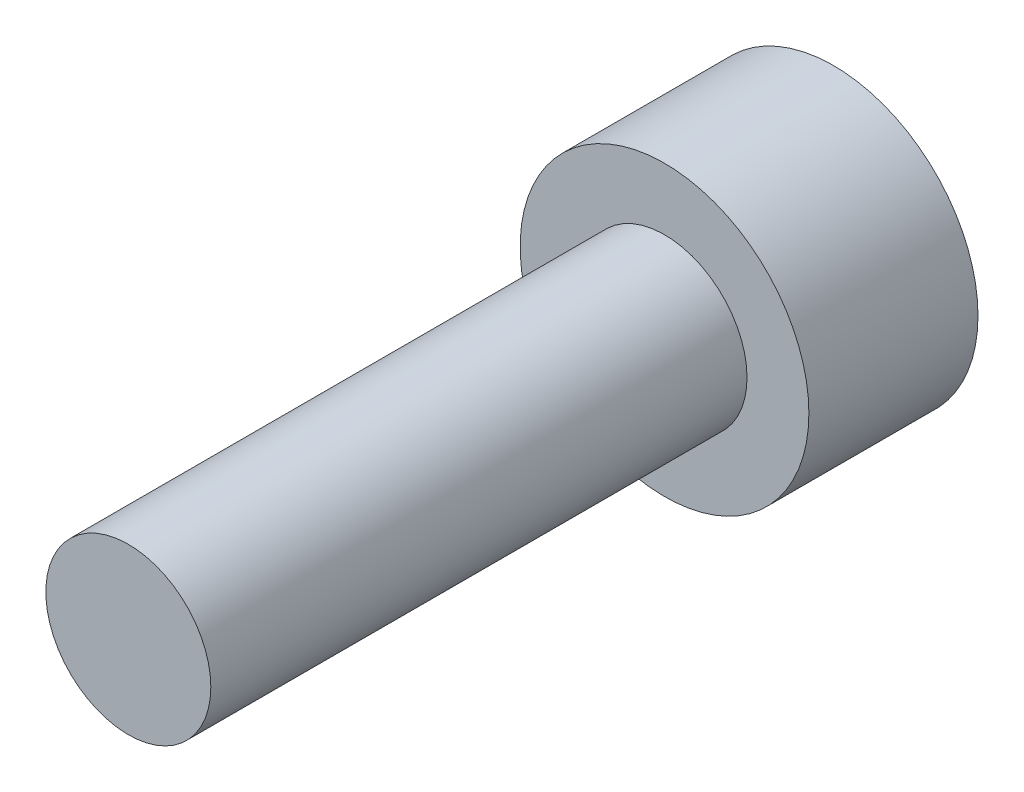
from build123d import *

# Parameters (mm, degrees)
SKETCH2_R           = 3.5
BOSS_EXTRUDE1_DEPTH = 4.1
SKETCH3_R           = 2
BOSS_EXTRUDE2_DEPTH = 13


with BuildPart() as part:
    # Sketch2 → Boss-Extrude1 (new body)
    with BuildSketch(Plane.XY):
        Circle(SKETCH2_R)
    extrude(amount=BOSS_EXTRUDE1_DEPTH)

    # Sketch3 → Boss-Extrude2 (add)
    with BuildSketch(Plane.XY.offset(4.1)):
        Circle(SKETCH3_R)
    extrude(amount=BOSS_EXTRUDE2_DEPTH)


solid = part.part
